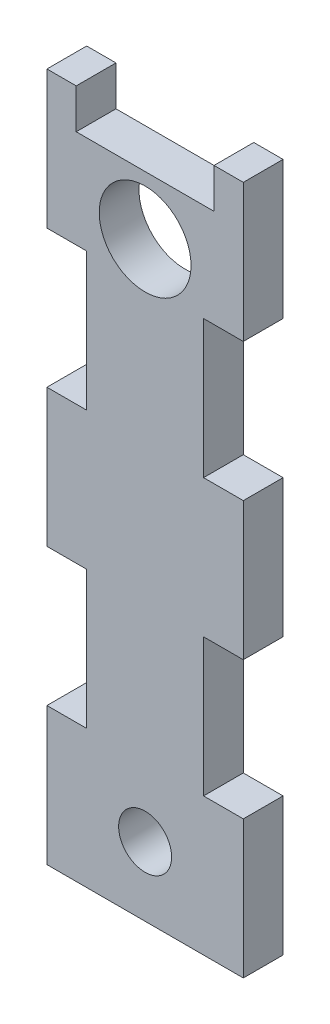
from build123d import *

# Parameters (mm, degrees)
SKETCH1_R               = 11
BOSS_EXTRUDE1_DEPTH     = 9.525
SKETCH3_R               = 6.35
CUT_EXTRUDE1_DEPTH      = 1
CUT_EXTRUDE1_DEPTH_BACK = 10.525


with BuildPart() as part:
    # Sketch1 → Boss-Extrude1 (new body)
    with BuildSketch(Plane.XY):
        Polygon((0, 0), (0, -33.02), (9.525, -33.02), (9.525, -66.04), (0, -66.04), (0, -99.06), (9.525, -99.06), (9.525, -132.08), (0, -132.08), (0, -165.1), (47.05, -165.1), (47.05, -132.08), (37.525, -132.08), (37.525, -99.06), (47.05, -99.06), (47.05, -66.04), (37.525, -66.04), (37.525, -33.02), (47.05, -33.02), (47.05, 0), (40.03499994, 0), (40.03499994, -9.525), (7.01499994, -9.525), (7.01499994, 0), align=None)
        with Locations((23.525, -23.525)):
            Circle(SKETCH1_R, mode=Mode.SUBTRACT)
    extrude(amount=BOSS_EXTRUDE1_DEPTH)

    # Sketch3 → Cut-Extrude1 (cut, two sides)
    with BuildSketch(Plane(origin=(0, 0, 0), x_dir=(-1, 0, 0), z_dir=(0, 0, -1))) as cut_extrude1_sk:
        with Locations((-23.525, -148.59)):
            Circle(SKETCH3_R)
    extrude(amount=CUT_EXTRUDE1_DEPTH, mode=Mode.SUBTRACT)
    extrude(cut_extrude1_sk.sketch, amount=-CUT_EXTRUDE1_DEPTH_BACK, mode=Mode.SUBTRACT)


solid = part.part
